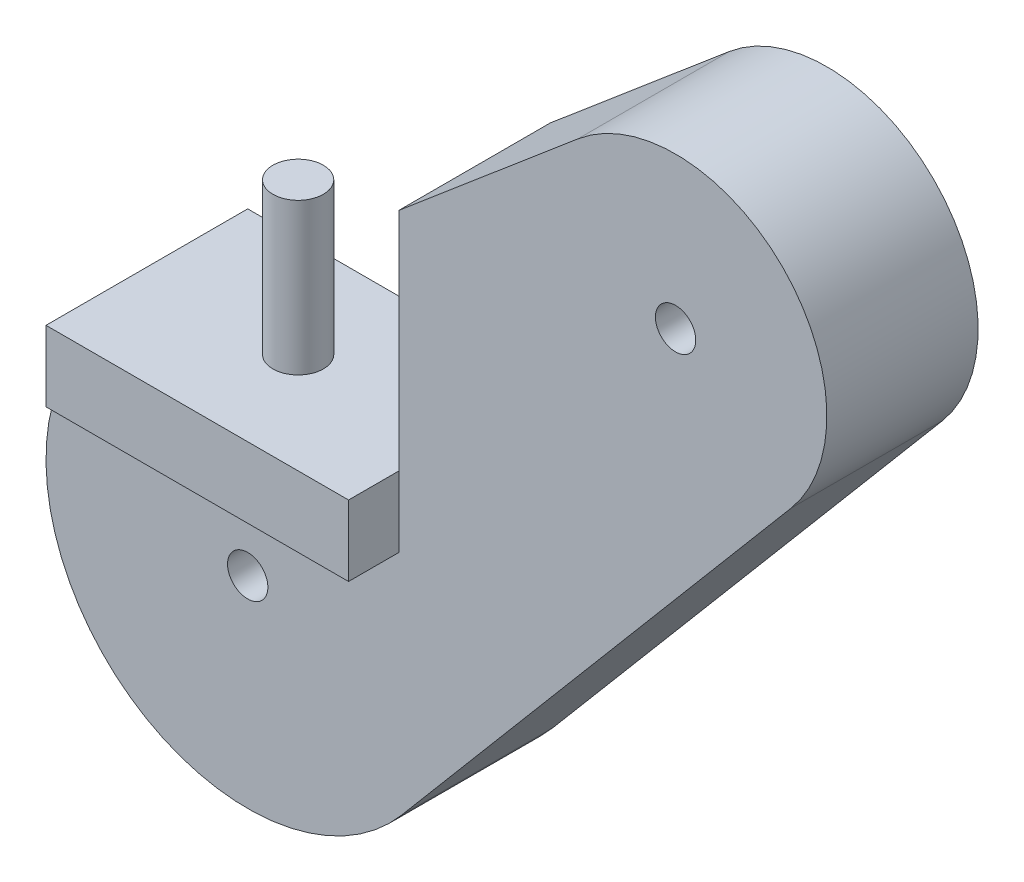
from build123d import *

# Parameters (mm, degrees)
BOSS_EXTRUDE1_DEPTH      = 15
CUT_EXTRUDE1_DEPTH       = 83.586829533
CUT_EXTRUDE1_DEPTH_BACK  = 83.586829533
SKETCH2_R                = 2
BOSS_EXTRUDE2_DEPTH      = 5
BOSS_EXTRUDE2_DEPTH_BACK = 15
SKETCH3_W                = 30
SKETCH3_H                = 7
CUT_EXTRUDE2_DEPTH       = 83.586829533
CUT_EXTRUDE2_DEPTH_BACK  = 83.586829533
SKETCH4_W                = 38.205528846
SKETCH4_H                = 30.397050351
SKETCH5_R                = 2.5
BOSS_EXTRUDE3_DEPTH      = 15


with BuildPart() as part:
    # Sketch1 → Boss-Extrude1 (new body)
    with BuildSketch(Plane.XY):
        with BuildLine():
            Line((-12.914434136, 15.27145674), (32.740581269, 53.879999426))
            ThreePointArc((32.740581269, 53.879999426), (53.033008589, 53.033008589), (53.879999426, 32.740581269))
            Line((53.879999426, 32.740581269), (15.27145674, -12.914434136))
            ThreePointArc((15.27145674, -12.914434136), (-14.142135624, -14.142135624), (-12.914434136, 15.27145674))
        make_face()
    extrude(amount=BOSS_EXTRUDE1_DEPTH)

    # Sketch2 → Cut-Extrude1 (cut, two sides: drawn at the far end of the back side and taken through both)
    with BuildSketch(Plane.XY.offset(15).offset(-CUT_EXTRUDE1_DEPTH_BACK)):
        Circle(SKETCH2_R)
        with Locations((42.426406871, 42.426406871)):
            Circle(SKETCH2_R)
    extrude(amount=CUT_EXTRUDE1_DEPTH + CUT_EXTRUDE1_DEPTH_BACK, mode=Mode.SUBTRACT)

    # Sketch3 → Boss-Extrude2 (add, two sides: drawn at the far end of the back side and taken through both)
    with BuildSketch(Plane.XY.offset(15).offset(-BOSS_EXTRUDE2_DEPTH_BACK)):
        with Locations((0, 13)):
            Rectangle(SKETCH3_W, SKETCH3_H)
    extrude(amount=BOSS_EXTRUDE2_DEPTH + BOSS_EXTRUDE2_DEPTH_BACK)

    # Sketch4 → Cut-Extrude2 (cut, two sides: drawn at the far end of the back side and taken through both)
    with BuildSketch(Plane.XY.offset(15).offset(-CUT_EXTRUDE2_DEPTH_BACK)):
        with Locations((-4.102764423, 31.698525176)):
            Rectangle(SKETCH4_W, SKETCH4_H)
    extrude(amount=CUT_EXTRUDE2_DEPTH + CUT_EXTRUDE2_DEPTH_BACK, mode=Mode.SUBTRACT)

    # Sketch5 → Boss-Extrude3 (add)
    with BuildSketch(Plane(origin=(0, 16.5, 0), x_dir=(1, 0, 0), z_dir=(0, 1, 0))):
        with Locations((0, -10)):
            Circle(SKETCH5_R)
    extrude(amount=BOSS_EXTRUDE3_DEPTH)


solid = part.part
